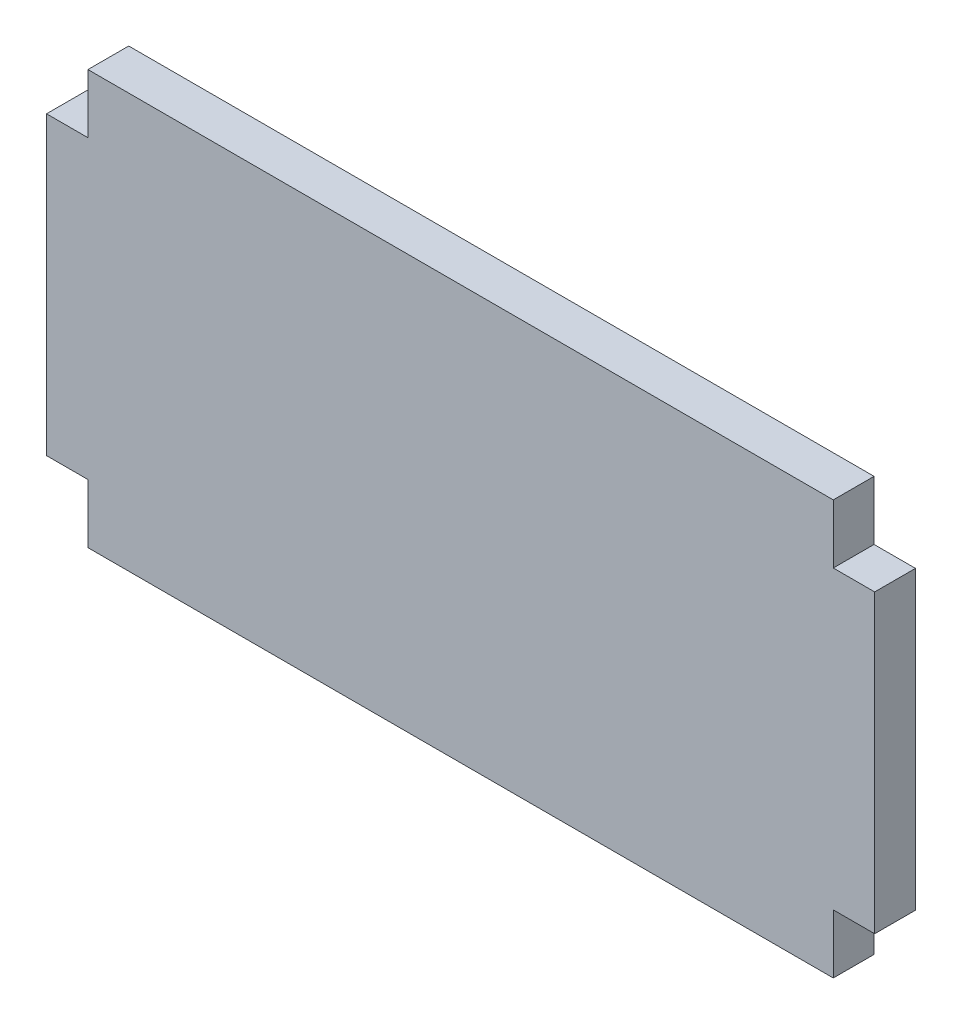
from build123d import *

# Parameters (mm, degrees)
BOSS_EXTRUDE1_DEPTH = 5.0038


with BuildPart() as part:
    # Sketch1 → Boss-Extrude1 (new body)
    with BuildSketch(Plane.XY):
        Polygon((-45.72, 25.4), (-45.72, 18.161), (-50.8, 18.161), (-50.8, -18.161), (-45.72, -18.161), (-45.72, -25.4), (45.72, -25.4), (45.72, -18.161), (50.8, -18.161), (50.8, 18.161), (45.72, 18.161), (45.72, 25.4), align=None)
    extrude(amount=BOSS_EXTRUDE1_DEPTH)


solid = part.part
